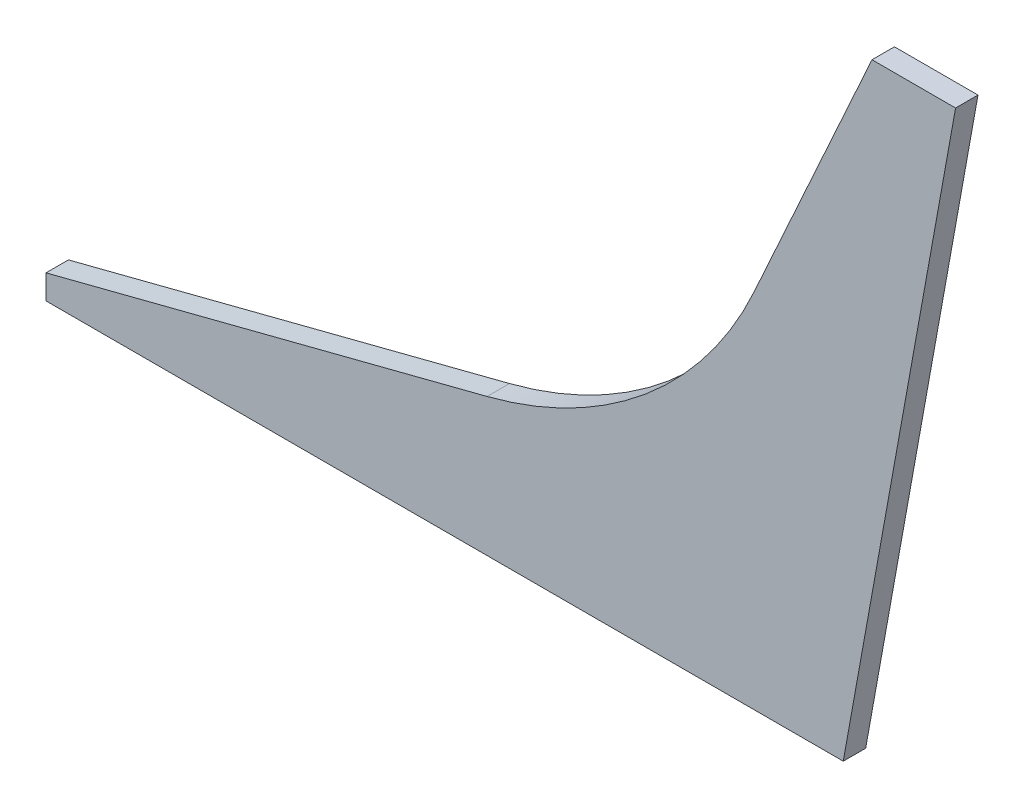
from build123d import *

# Parameters (mm, degrees)
BOSS_EXTRUDE1_DEPTH     = 15
CUT_EXTRUDE1_DEPTH      = 1
CUT_EXTRUDE1_DEPTH_BACK = 16


with BuildPart() as part:
    # Sketch1 → Boss-Extrude1 (new body)
    with BuildSketch(Plane.XY):
        with BuildLine():
            Line((-236.729376996, 0), (0, 0))
            Line((0, 0), (357.876847169, 0))
            Line((357.876847169, 0), (396.730398779, 416))
            Line((396.730398779, 416), (315.832809595, 416))
            Line((315.832809595, 416), (236.983089551, 242.144494596))
            ThreePointArc((236.983089551, 242.144494596), (164.696190822, 146.877858304), (58.352308735, 92.177707838))
            Line((58.352308735, 92.177707838), (-236.729376996, 16.274880501))
            Line((-236.729376996, 16.274880501), (-236.729376996, 0))
        make_face()
    extrude(amount=BOSS_EXTRUDE1_DEPTH)

    # Sketch2 → Cut-Extrude1 (cut, two sides)
    with BuildSketch(Plane.XY.offset(15)) as cut_extrude1_sk:
        Polygon((396.730398779, 416), (357.876847169, 0), (296.597151769, 0), (371.734942748, 416), align=None)
    extrude(amount=CUT_EXTRUDE1_DEPTH, mode=Mode.SUBTRACT)
    extrude(cut_extrude1_sk.sketch, amount=-CUT_EXTRUDE1_DEPTH_BACK, mode=Mode.SUBTRACT)


solid = part.part
